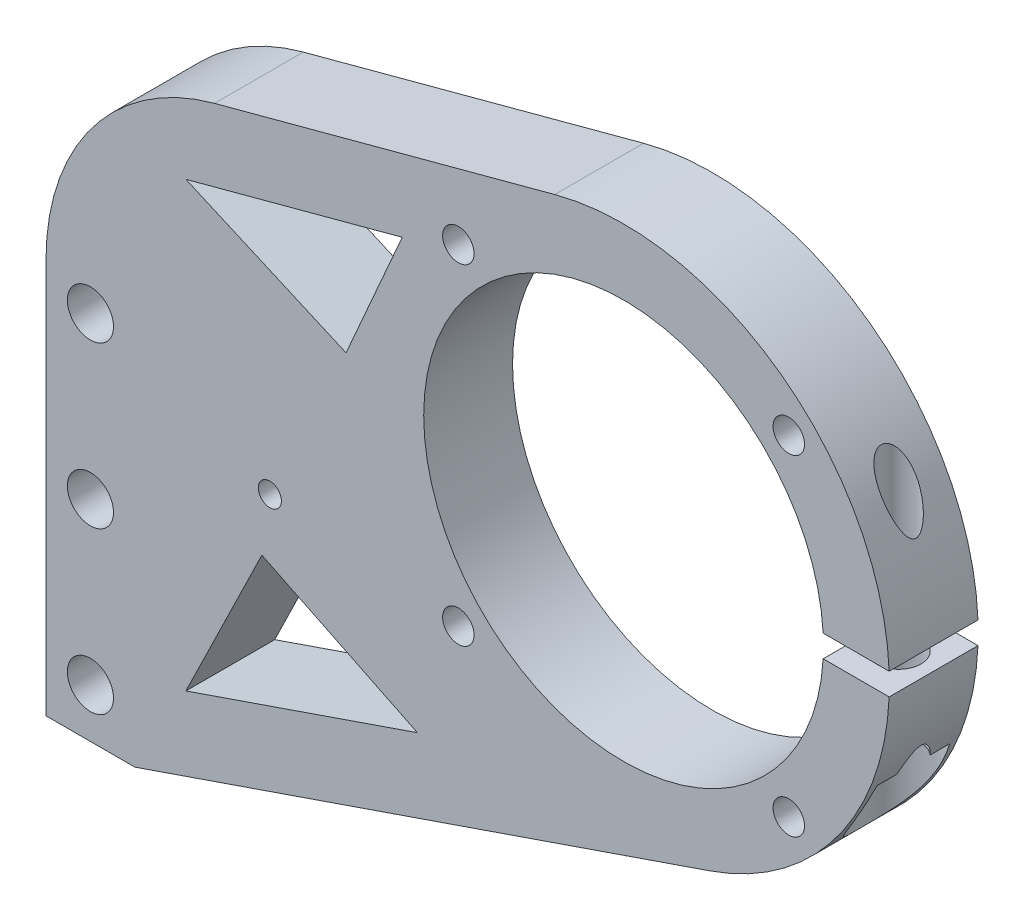
from build123d import *

# Parameters (mm, degrees)
BOSS_EXTRUDE1_DEPTH        = 12.7
CUT_EXTRUDE1_DEPTH         = 270.1976912701424
F_8_CLEARANCE_HOLE1_D      = 4.5
F_1_4_CLEARANCE_HOLE1_D    = 6.6
F_12_CLEARANCE_HOLE1_D     = 6
HOLE1_D                    = 6.4
HOLE1_DEPTH                = 24.77643101
HOLE1_CBORE_D              = 11.2
HOLE1_CBORE_DEPTH          = 11.77643101
F_10_CLEARANCE_HOLE1_D     = 5
F_10_CLEARANCE_HOLE1_DEPTH = 36.4125
CHAMFER1_SIZE              = 3.0000000000270917
SKETCH14_R                 = 2.9999999999999645
SKETCH14_R_2               = 1.6510000000000182
BOSS_EXTRUDE2_DEPTH        = 12.7
FILLET_1_R                 = 10
CUT_EXTRUDE_1_DEPTH        = 270.1976913300265
CUT_EXTRUDE_1_DEPTH_BACK   = 270.1976913300265
CUT_EXTRUDE_2_DEPTH        = 270.1976913300265


with BuildPart() as part:
    # Sketch1 → Boss-Extrude1 (new body)
    with BuildSketch(Plane(origin=(0, 0, 0), x_dir=(-1, 0, 0), z_dir=(0, 0, -1))):
        with BuildLine():
            Line((224.16945546503186, 127.72254562005153), (151.435240745465, 147.21161971627112))
            ThreePointArc((151.435240745465, 147.21161971627112), (105.25775385063858, 121.60745801933766), (129.24653278741587, 74.57053765621215))
            Line((129.24653278741587, 74.57053765621215), (211.46945546503187, 46.304993077870854))
            Line((211.46945546503187, 46.304993077870854), (224.16945546503186, 46.304993077870854))
            Line((224.16945546503186, 46.304993077870854), (224.16945546503186, 127.72254562005153))
        make_face()
    extrude(amount=-BOSS_EXTRUDE1_DEPTH)

    # Sketch2 → Cut-Extrude1 (cut, through all)
    with BuildSketch(Plane.XY.offset(12.7)):
        with BuildLine():
            Line((-103.63329146305492, 112.0939383172865), (-113.17901851462243, 112.0939383172865))
            ThreePointArc((-113.17901851462243, 112.0939383172865), (-113.13471703156931, 110.50643831728651), (-113.17901851462243, 108.9189383172865))
            Line((-113.17901851462243, 108.9189383172865), (-103.6332914630549, 108.91893831728652))
            ThreePointArc((-103.6332914630549, 108.91893831728652), (-103.60011703156931, 110.50643831728651), (-103.63329146305492, 112.0939383172865))
        make_face()
    extrude(amount=-CUT_EXTRUDE1_DEPTH, mode=Mode.SUBTRACT)

    # Sketch3 → Cut-Revolve1 (revolve, cut)
    with BuildSketch(Plane(origin=(0, 110.50643831728648, 0), x_dir=(1, 0, 0), z_dir=(0, 1, 0))):
        Polygon((-113.02511703156932, 3.5e-15), (-141.60011703156934, 0), (-141.60011703156934, -12.7), (-113.02511703156932, -12.7), align=None)
    revolve(axis=Axis((-141.60011703156934, 110.50643831728648, 0), (0, 0, 1)), mode=Mode.SUBTRACT)

    # #8 Clearance Hole1 (through all)
    with Locations(Plane.XY.offset(12.7)):
        with Locations((-117.978117032, 86.884438317), (-165.222117032, 86.884438317), (-165.222117032, 134.128438317), (-117.978117032, 134.128438317)):
            Hole(F_8_CLEARANCE_HOLE1_D / 2)

    # 1/4 Clearance Hole1 (through all)
    with Locations(Plane(origin=(0, 0, 0), x_dir=(-1, 0, 0), z_dir=(0, 0, -1))):
        with Locations((217.819455465, 53.304993078), (217.819455465, 76.304993078), (217.819455465, 99.304993078)):
            Hole(F_1_4_CLEARANCE_HOLE1_D / 2)

    # #12 Clearance Hole1 (through all)
    with Locations(Plane.XY.offset(12.7)):
        with Locations((-192.169455465, 89.72254562)):
            Hole(F_12_CLEARANCE_HOLE1_D / 2)

    # Hole1
    with Locations(Plane(origin=(0, 84.14250730723957, 0), x_dir=(-1, 0, 0), z_dir=(0, -1, 0))):
        with Locations((108.633291463, -6.35)):
            CounterBoreHole(HOLE1_D / 2, HOLE1_CBORE_D / 2, HOLE1_CBORE_DEPTH, depth=HOLE1_DEPTH)

    # #10 Clearance Hole1
    with Locations(Plane(origin=(0, 112.0939383172865, 0), x_dir=(-1, 0, 0), z_dir=(0, -1, 0))):
        with Locations((108.633291463, -6.35)):
            Hole(F_10_CLEARANCE_HOLE1_D / 2, depth=F_10_CLEARANCE_HOLE1_DEPTH)

    # Chamfer1
    chamfer1_edges = [part.edges().sort_by_distance(p)[0] for p in [
        (-221.11945546500002, 99.304993078, 0),
        (-221.11945546500002, 76.304993078, 0),
        (-221.11945546500002, 53.304993078, 0),
    ]]
    chamfer(chamfer1_edges, length=CHAMFER1_SIZE)

    # Sketch14 → Boss-Extrude2 (add)
    with BuildSketch(Plane(origin=(0, 0, 0), x_dir=(-1, 0, 0), z_dir=(0, 0, -1))):
        with Locations((192.16945546503186, 89.72254562005152)):
            Circle(SKETCH14_R)
        with Locations((192.16945546503186, 89.72254562005152)):
            Circle(SKETCH14_R_2, mode=Mode.SUBTRACT)
    extrude(amount=-BOSS_EXTRUDE2_DEPTH)

    # 圆角1
    fillet_1_edges = [part.edges().sort_by_distance(p)[0] for p in [
        (-224.16945546503186, 127.72254562005153, 6.35),
    ]]
    fillet(fillet_1_edges, radius=FILLET_1_R)

    # 草图1 → 切除-拉伸1 (cut, two sides: drawn at the far end of the back side and taken through both)
    with BuildSketch(Plane(origin=(0, 0, 0), x_dir=(-1, 0, 0), z_dir=(0, 0, -1)).offset(-CUT_EXTRUDE_1_DEPTH_BACK)):
        with BuildLine():
            Line((499.3977697015972, 53.97534108618588), (216.75764591605704, 129.7085340031526))
            Line((216.75764591605704, 129.7085340031526), (200.08107443086368, 134.17700786512998))
            ThreePointArc((200.08107443086368, 134.17700786512998), (217.45343902449696, 122.56916495351871), (224.16945546503186, 102.78441851073525))
            Line((224.16945546503186, 102.78441851073525), (224.16945546503186, 120.04927574026192))
            Line((224.16945546503186, 120.04927574026192), (224.16945546503186, 412.65986352358874))
            Line((224.16945546503186, 412.65986352358874), (-240.11771897993546, 56.399784399468274))
            Line((-240.11771897993546, 56.399784399468274), (35.11059525662989, -302.2847380379346))
            Line((35.11059525662989, -302.2847380379346), (499.3977697015972, 53.97534108618588))
        make_face()
    extrude(amount=CUT_EXTRUDE_1_DEPTH + CUT_EXTRUDE_1_DEPTH_BACK, mode=Mode.SUBTRACT)

    # 草图2 → 切除-拉伸2 (cut, through all)
    with BuildSketch(Plane(origin=(0, 0, 0), x_dir=(-1, 0, 0), z_dir=(0, 0, -1))):
        Polygon((171.07059959298968, 70.76717861409958), (204.1694554650319, 59.388877336589836), (193.30917816776565, 81.6274559113658), align=None)
        Polygon((181.27084732320867, 112.69613365514031), (173.24474011566244, 131.01502016859888), (204.1694554650319, 122.72876766457311), align=None)
    extrude(amount=-CUT_EXTRUDE_2_DEPTH, mode=Mode.SUBTRACT)


solid = part.part
